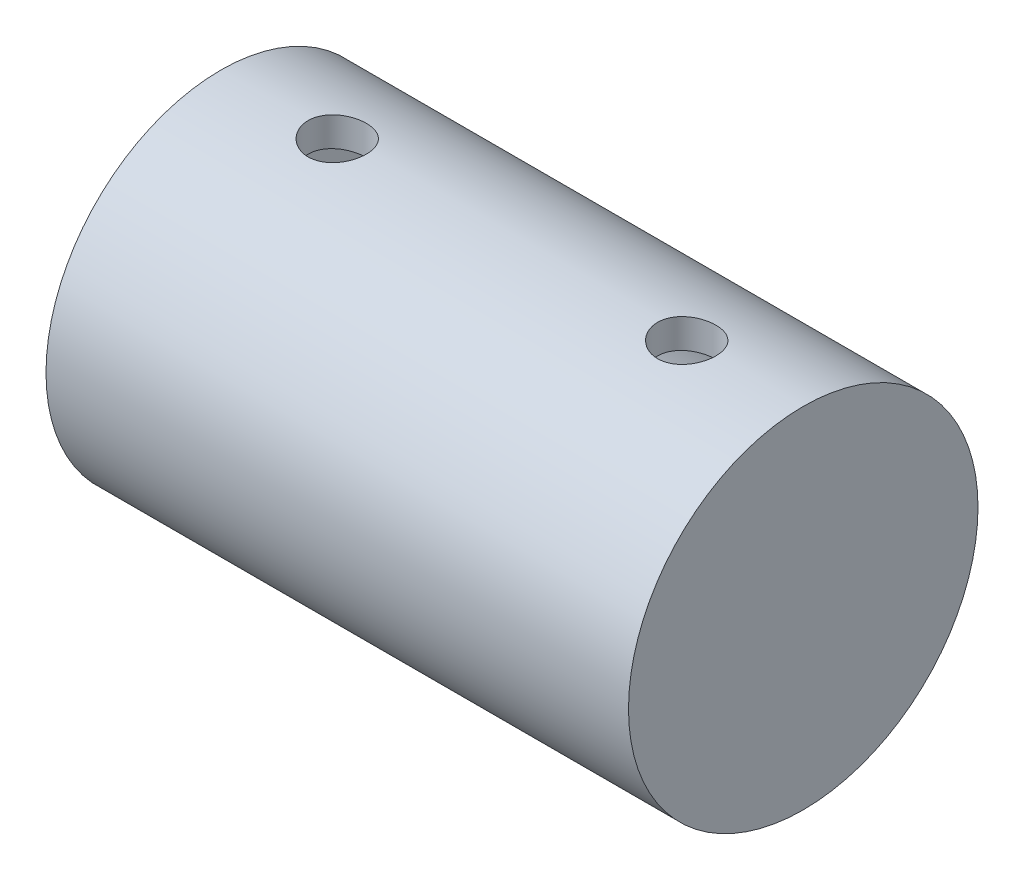
from build123d import *

# Parameters (mm, degrees)
SKETCH1_R           = 15
SKETCH1_R_2         = 12.5
BOSS_EXTRUDE1_DEPTH = 25
BOSS_EXTRUDE2_START = 20
SKETCH1_2_R         = 12.5
BOSS_EXTRUDE2_DEPTH = 5
BOSS_EXTRUDE3_START = -25
SKETCH1_3_R         = 12.5
BOSS_EXTRUDE3_DEPTH = 5
SKETCH2_R           = 2.5
CUT_EXTRUDE1_DEPTH  = 33.787192622


with BuildPart() as part:
    # Sketch1 → Boss-Extrude1 (new, symmetric)
    with BuildSketch(Plane(origin=(0, 0, 0), x_dir=(0, 0, -1), z_dir=(1, 0, 0))):
        Circle(SKETCH1_R)
        Circle(SKETCH1_R_2, mode=Mode.SUBTRACT)
    extrude(amount=BOSS_EXTRUDE1_DEPTH, both=True)

    # Sketch1_2 → Boss-Extrude2 (add)
    with BuildSketch(Plane(origin=(0, 0, 0), x_dir=(0, 0, -1), z_dir=(1, 0, 0)).offset(BOSS_EXTRUDE2_START)):
        Circle(SKETCH1_2_R)
    extrude(amount=BOSS_EXTRUDE2_DEPTH)

    # Sketch1_3 → Boss-Extrude3 (add)
    with BuildSketch(Plane(origin=(0, 0, 0), x_dir=(0, 0, -1), z_dir=(1, 0, 0)).offset(BOSS_EXTRUDE3_START)):
        Circle(SKETCH1_3_R)
    extrude(amount=BOSS_EXTRUDE3_DEPTH)

    # Sketch2 → Cut-Extrude1 (cut, through all)
    with BuildSketch(Plane(origin=(0, 0, 0), x_dir=(1, 0, 0), z_dir=(0, 1, 0))):
        with Locations((-15, 0)):
            Circle(SKETCH2_R)
        with Locations((15, 0)):
            Circle(SKETCH2_R)
    extrude(amount=CUT_EXTRUDE1_DEPTH, mode=Mode.SUBTRACT)


solid = part.part
